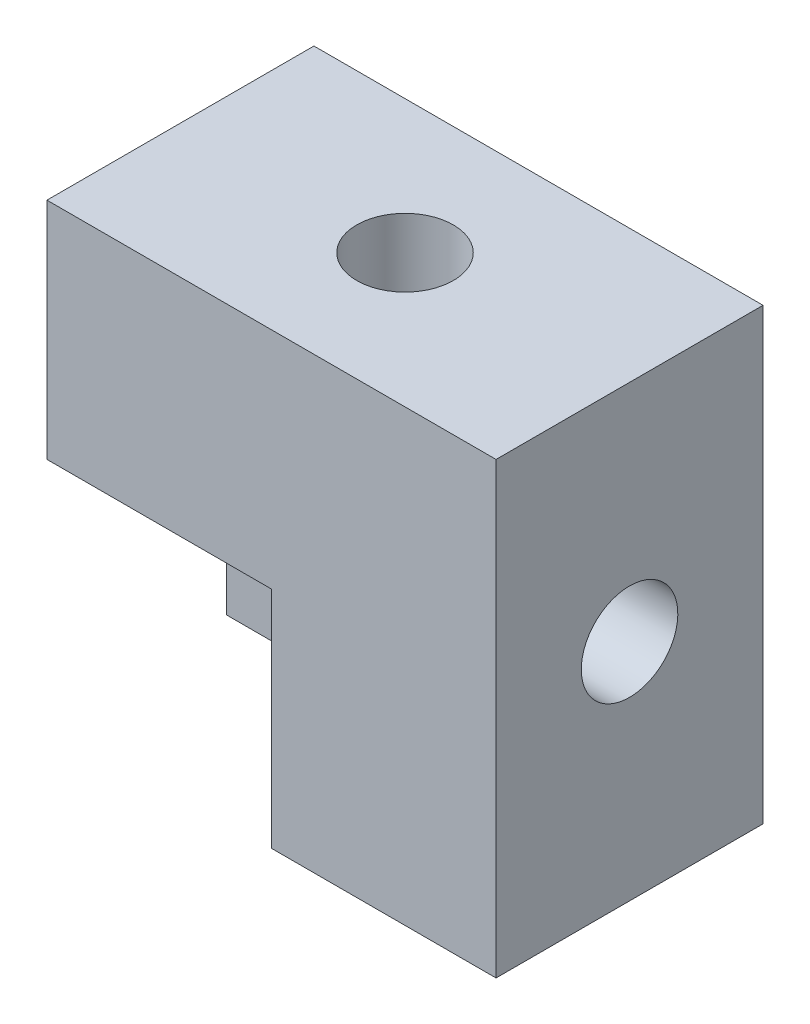
from build123d import *

# Parameters (mm, degrees)
SKETCH1_W           = 20
SKETCH1_H           = 20
BOSS_EXTRUDE1_DEPTH = 11.89
SKETCH2_W           = 10
SKETCH2_H           = 10
CUT_EXTRUDE1_DEPTH  = 8
SKETCH101_R         = 2.15
CUT_EXTRUDE92_DEPTH = 6.825
SKETCH100_R         = 2.15
CUT_EXTRUDE93_DEPTH = 6.875
SKETCH99_R          = 2.15
CUT_EXTRUDE94_DEPTH = 4.825


with BuildPart() as part:
    # Sketch1 → Boss-Extrude1 (new body)
    with BuildSketch(Plane.XY):
        with Locations((10, 10)):
            Rectangle(SKETCH1_W, SKETCH1_H)
    extrude(amount=BOSS_EXTRUDE1_DEPTH)

    # Sketch2 → Cut-Extrude1 (cut)
    with BuildSketch(Plane.XY.offset(11.89)):
        with Locations((5, 5)):
            Rectangle(SKETCH2_W, SKETCH2_H)
    extrude(amount=-CUT_EXTRUDE1_DEPTH, mode=Mode.SUBTRACT)

    # Sketch101 → Cut-Extrude92 (cut)
    with BuildSketch(Plane(origin=(0, 20, 0), x_dir=(1, 0, 0), z_dir=(0, 1, 0))):
        with Locations((10, -5.945)):
            Circle(SKETCH101_R)
    extrude(amount=-CUT_EXTRUDE92_DEPTH, mode=Mode.SUBTRACT)

    # Sketch100 → Cut-Extrude93 (cut)
    with BuildSketch(Plane(origin=(20, 0, 0), x_dir=(0, 0, -1), z_dir=(1, 0, 0))):
        with Locations((-5.945, 10)):
            Circle(SKETCH100_R)
    extrude(amount=-CUT_EXTRUDE93_DEPTH, mode=Mode.SUBTRACT)

    # Sketch99 → Cut-Extrude94 (cut)
    with BuildSketch(Plane(origin=(0, 0, 0), x_dir=(-1, 0, 0), z_dir=(0, 0, -1))):
        with Locations((-15, 15)):
            Circle(SKETCH99_R)
    extrude(amount=-CUT_EXTRUDE94_DEPTH, mode=Mode.SUBTRACT)


solid = part.part
